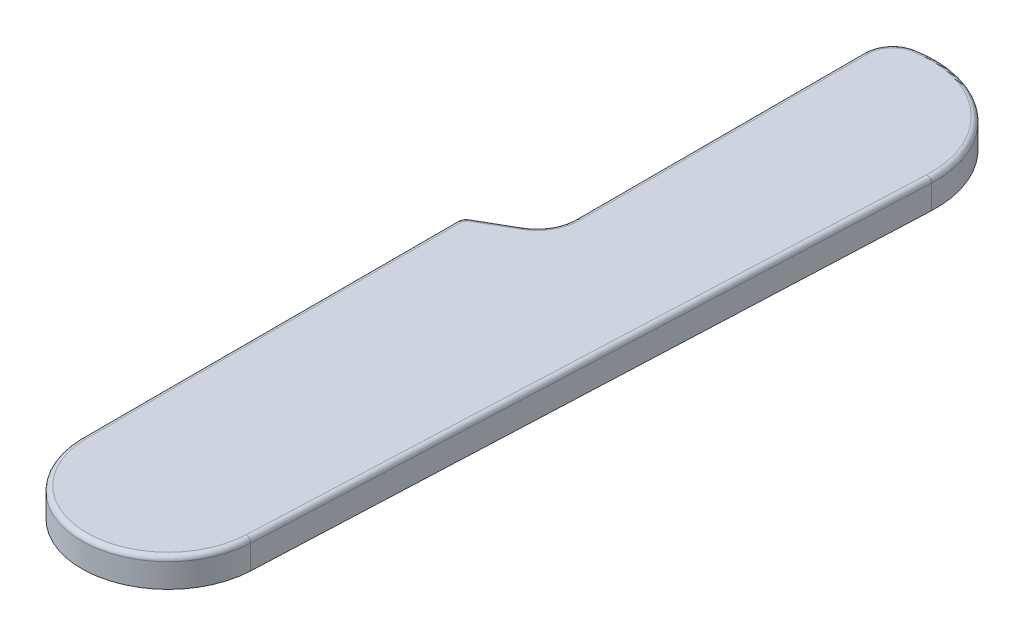
from build123d import *

# Parameters (mm, degrees)
BOSS_EXTRUDE1_DEPTH = 3
FILLET1_R           = 4
FILLET2_R           = 3
FILLET3_R           = 1
FILLET4_R           = 0.5
SKETCH2_R           = 1
CUT_EXTRUDE1_DEPTH  = 2.3


with BuildPart() as part:
    # Sketch1 → Boss-Extrude1 (new body)
    with BuildSketch(Plane(origin=(0, 0, 0), x_dir=(1, 0, 0), z_dir=(0, 1, 0))):
        with BuildLine():
            Line((8.991433994, -0.392574486), (11.957374237, 67.538625463))
            ThreePointArc((11.957374237, 67.538625463), (7.303664413, 76.769797523), (-2.998880838, 77.623679297))
            Line((-2.998880838, 77.623679297), (-2.998880838, 43.087780912))
            Line((-2.998880838, 43.087780912), (-8.998880838, 39.623679297))
            Line((-8.998880838, 39.623679297), (-8.998880838, -0.141928385))
            ThreePointArc((-8.998880838, -0.141928385), (-0.125378351, -8.999126639), (8.991433994, -0.392574486))
        make_face()
    extrude(amount=BOSS_EXTRUDE1_DEPTH)

    # Fillet1
    fillet1_edges = [part.edges().sort_by_distance(p)[0] for p in [
        (-2.998880838, 1.5, -43.087780912),
    ]]
    fillet(fillet1_edges, radius=FILLET1_R)

    # Fillet2
    fillet2_edges = [part.edges().sort_by_distance(p)[0] for p in [
        (-2.998880838, 1.5, -77.623679297),
    ]]
    fillet(fillet2_edges, radius=FILLET2_R)

    # Fillet3
    fillet3_edges = [part.edges().sort_by_distance(p)[0] for p in [
        (-8.998880838, 1.5, -39.623679297),
    ]]
    fillet(fillet3_edges, radius=FILLET3_R)

    # Fillet4
    fillet4_edges = [part.edges().sort_by_distance(p)[0] for p in [
        (10.474404116, 3, -33.573025488),
        (-0.125378351, 3, 8.999126639),
        (-8.998880838, 3, -19.452200321),
        (-2.998880838, 3, -60.423029196),
        (-3.534779223, 3, -43.397181989),
        (8.325091375, 3, -75.986589378),
        (-2.306460594, 3, -77.365925089),
        (-6.748880838, 3, -40.922717403),
        (-8.864906242, 3, -39.546329028),
    ]]
    fillet(fillet4_edges, radius=FILLET4_R)

    # Sketch2 → Cut-Extrude1 (cut)
    with BuildSketch(Plane(origin=(0, 0, 0), x_dir=(-1, 0, 0), z_dir=(0, -1, 0))):
        with Locations((-6.916463595, 69.482266802)):
            Circle(SKETCH2_R)
        with Locations((-2.740849282, 1.610591965)):
            Circle(SKETCH2_R)
        with Locations((6, 35.355339106)):
            Circle(SKETCH2_R)
    extrude(amount=-CUT_EXTRUDE1_DEPTH, mode=Mode.SUBTRACT)


solid = part.part
